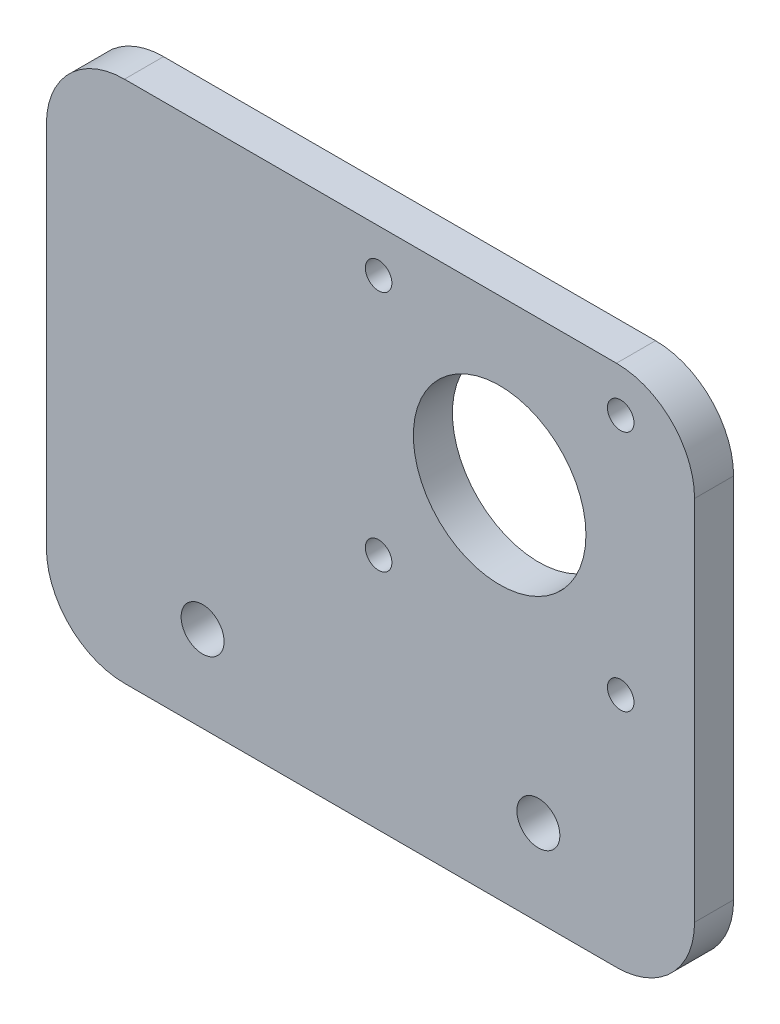
from build123d import *

# Parameters (mm, degrees)
SKETCH1_W            = 83
SKETCH1_H            = 67
BOSS_EXTRUDE1_DEPTH  = 5
M5_CLEARANCE_HOLE1_D = 5.5
M3_CLEARANCE_HOLE1_D = 3.4
SKETCH6_R            = 11.05
CUT_EXTRUDE1_DEPTH   = 6
FILLET1_R            = 10


with BuildPart() as part:
    # Sketch1 → Boss-Extrude1 (new body)
    with BuildSketch(Plane.XY):
        Rectangle(SKETCH1_W, SKETCH1_H)
    extrude(amount=BOSS_EXTRUDE1_DEPTH)

    # M5 Clearance Hole1 (through all)
    with Locations(Plane.XY.offset(5)):
        with Locations((21.5, -22.5), (-21.5, -22.5)):
            Hole(M5_CLEARANCE_HOLE1_D / 2)

    # M3 Clearance Hole1 (through all)
    with Locations(Plane(origin=(0, 0, 0), x_dir=(-1, 0, 0), z_dir=(0, 0, -1))):
        with Locations((-32.041076253, 28.00000478), (-1.041076253, 28.00000478), (-1.041076253, -2.99999522), (-32.041076253, -2.99999522)):
            Hole(M3_CLEARANCE_HOLE1_D / 2)

    # Sketch6 → Cut-Extrude1 (cut, through all)
    with BuildSketch(Plane.XY.offset(5)):
        with Locations((16.541076624, 12.500005008)):
            Circle(SKETCH6_R)
    extrude(amount=-CUT_EXTRUDE1_DEPTH, mode=Mode.SUBTRACT)

    # Fillet1
    fillet1_edges = [part.edges().sort_by_distance(p)[0] for p in [
        (41.5, -33.5, 2.5),
        (-41.5, -33.5, 2.5),
        (-41.5, 33.5, 2.5),
        (41.5, 33.5, 2.5),
    ]]
    fillet(fillet1_edges, radius=FILLET1_R)


solid = part.part
